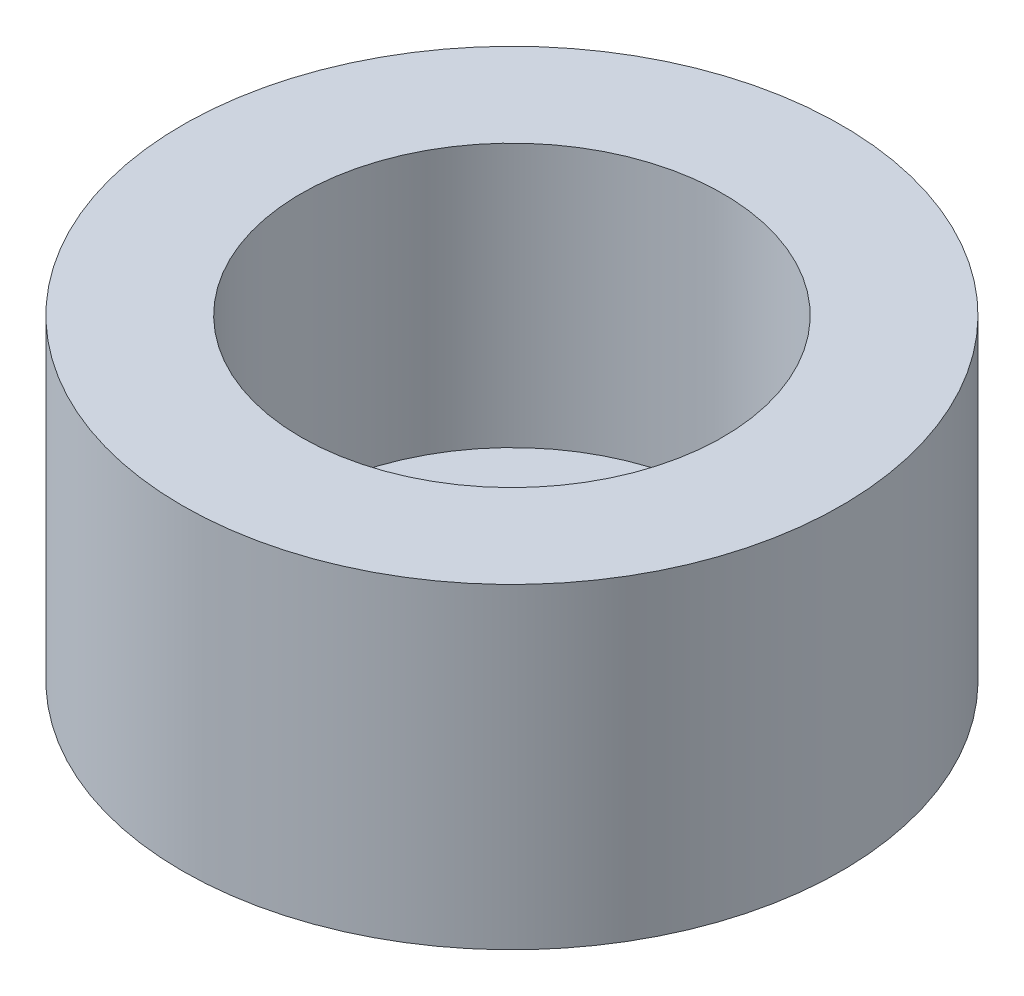
from build123d import *

# Parameters (mm, degrees)
SKETCH1_R           = 12.5
BOSS_EXTRUDE1_DEPTH = 2
SKETCH2_R           = 12.5
SKETCH2_R_2         = 8
BOSS_EXTRUDE2_DEPTH = 10
SKETCH3_R           = 2.1
CUT_EXTRUDE1_DEPTH  = 10


with BuildPart() as part:
    # Sketch1 → Boss-Extrude1 (new body)
    with BuildSketch(Plane(origin=(0, 0, 0), x_dir=(1, 0, 0), z_dir=(0, 1, 0))):
        Circle(SKETCH1_R)
    extrude(amount=BOSS_EXTRUDE1_DEPTH)

    # Sketch2 → Boss-Extrude2 (add)
    with BuildSketch(Plane(origin=(0, 2, 0), x_dir=(1, 0, 0), z_dir=(0, 1, 0))):
        Circle(SKETCH2_R)
        Circle(SKETCH2_R_2, mode=Mode.SUBTRACT)
    extrude(amount=BOSS_EXTRUDE2_DEPTH)

    # Sketch3 → Cut-Extrude1 (cut)
    with BuildSketch(Plane(origin=(0, 2, 0), x_dir=(1, 0, 0), z_dir=(0, 1, 0))):
        Circle(SKETCH3_R)
    extrude(amount=-CUT_EXTRUDE1_DEPTH, mode=Mode.SUBTRACT)


solid = part.part
